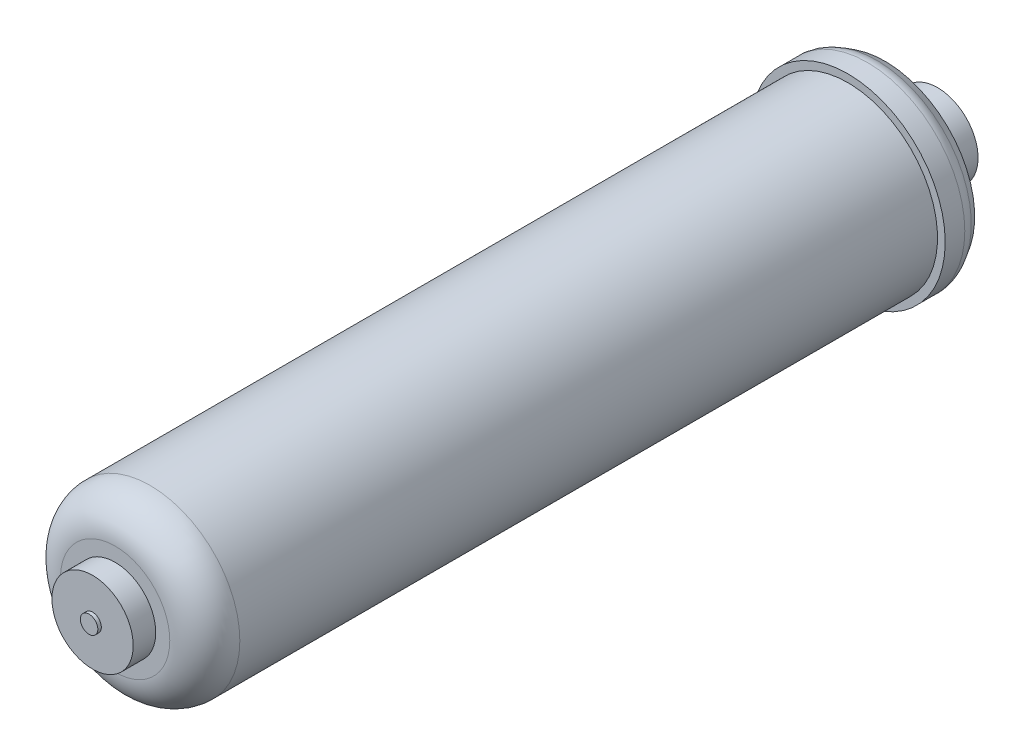
from build123d import *

# Parameters (mm, degrees)
FILLET1_R = 12.7
FILLET2_R = 6.35


with BuildPart() as part:
    # Sketch1 → Revolve1 (revolve)
    with BuildSketch(Plane(origin=(0, 0, 0), x_dir=(0, 0, -1), z_dir=(1, 0, 0))):
        Polygon((0, 0), (0, 3.175), (-1.27, 3.175), (-1.27, 14.732), (-9.398, 14.732), (-20.32, 32.555084127), (-24.892, 35.306), (-33.7566, 35.306), (-33.7566, 32.512), (-299.4152, 32.512), (-299.4152, 14.732), (-307.594, 14.732), (-307.594, 3.175), (-308.864, 3.175), (-308.864, 0), align=None)
    revolve(axis=Axis((0, 0, 0), (0, 0, 1)))

    # Fillet1
    fillet1_edges = [part.edges().sort_by_distance(p)[0] for p in [
        (0, -32.512, 299.4152),
    ]]
    fillet(fillet1_edges, radius=FILLET1_R)

    # Fillet2
    fillet2_edges = [part.edges().sort_by_distance(p)[0] for p in [
        (0, -35.306, 24.892),
    ]]
    fillet(fillet2_edges, radius=FILLET2_R)


solid = part.part
